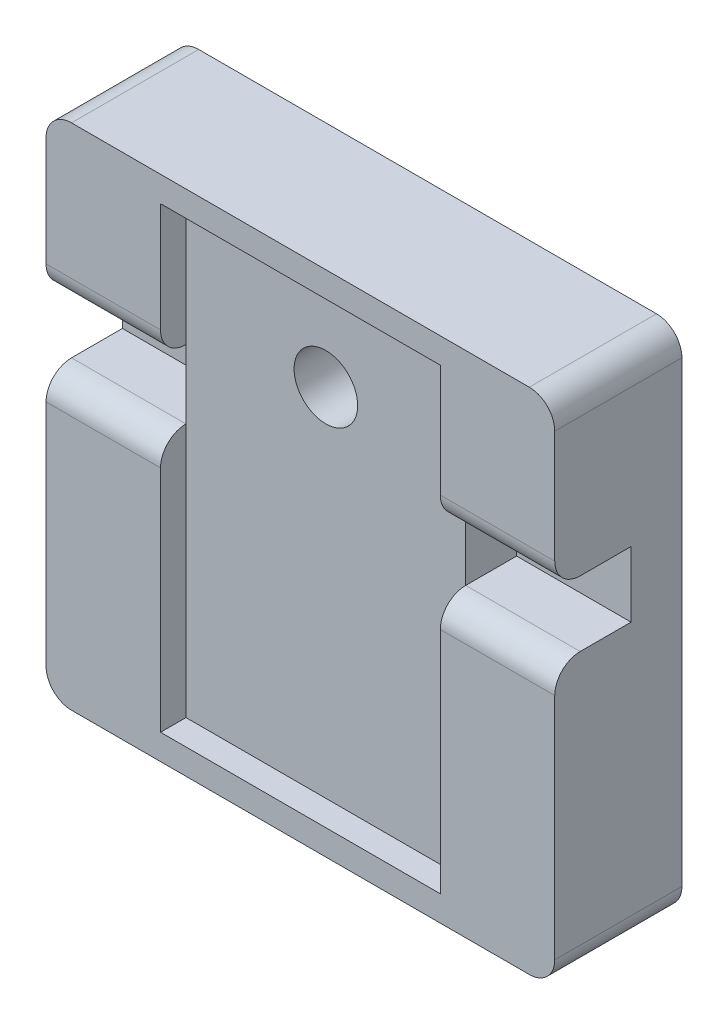
from build123d import *

# Parameters (mm, degrees)
SKETCH_1_W          = 20
SKETCH_1_H          = 20
EXTRUDE_1_DEPTH     = 5
SKETCH_2_W          = 11
SKETCH_2_H          = 18
SKETCH_2_R          = 1.25
CUT_EXTRUDE_1_DEPTH = 1
SKETCH_2_2_R        = 1.25
CUT_EXTRUDE_2_DEPTH = 16
SKETCH_3_W          = 4.5
SKETCH_3_H          = 2.7
SKETCH_3_H_2        = 2.574853583
CUT_EXTRUDE_3_DEPTH = 3
FILLET_1_R          = 1


with BuildPart() as part:
    # Эскиз1 → Бобышка-Вытянуть1 (new body)
    with BuildSketch(Plane.XY):
        Rectangle(SKETCH_1_W, SKETCH_1_H)
    extrude(amount=EXTRUDE_1_DEPTH)

    # Эскиз2 → Вырез-Вытянуть1 (cut)
    with BuildSketch(Plane.XY.offset(5)):
        Rectangle(SKETCH_2_W, SKETCH_2_H)
        with Locations((0, 5)):
            Circle(SKETCH_2_R, mode=Mode.SUBTRACT)
    extrude(amount=-CUT_EXTRUDE_1_DEPTH, mode=Mode.SUBTRACT)

    # Эскиз2<2> → Вырез-Вытянуть2 (cut, through all)
    with BuildSketch(Plane.XY.offset(5)):
        with Locations((0, 5)):
            Circle(SKETCH_2_2_R)
    extrude(amount=-CUT_EXTRUDE_2_DEPTH, mode=Mode.SUBTRACT)

    # Эскиз3 → Вырез-Вытянуть3 (cut)
    with BuildSketch(Plane.XY.offset(5)):
        with Locations((-7.75, 2.35)):
            Rectangle(SKETCH_3_W, SKETCH_3_H)
        with Locations((7.75, 2.287426792)):
            Rectangle(SKETCH_3_W, SKETCH_3_H_2)
    extrude(amount=-CUT_EXTRUDE_3_DEPTH, mode=Mode.SUBTRACT)

    # Скругление1
    fillet_1_edges = [part.edges().sort_by_distance(p)[0] for p in [
        (7.75, 1, 5),
        (7.75, 3.574853583, 5),
        (-7.75, 1, 5),
        (-7.75, 3.7, 5),
        (-10, -10, 2.5),
        (10, -10, 2.5),
        (10, 10, 2.5),
        (-10, 10, 2.5),
    ]]
    fillet(fillet_1_edges, radius=FILLET_1_R)


solid = part.part
